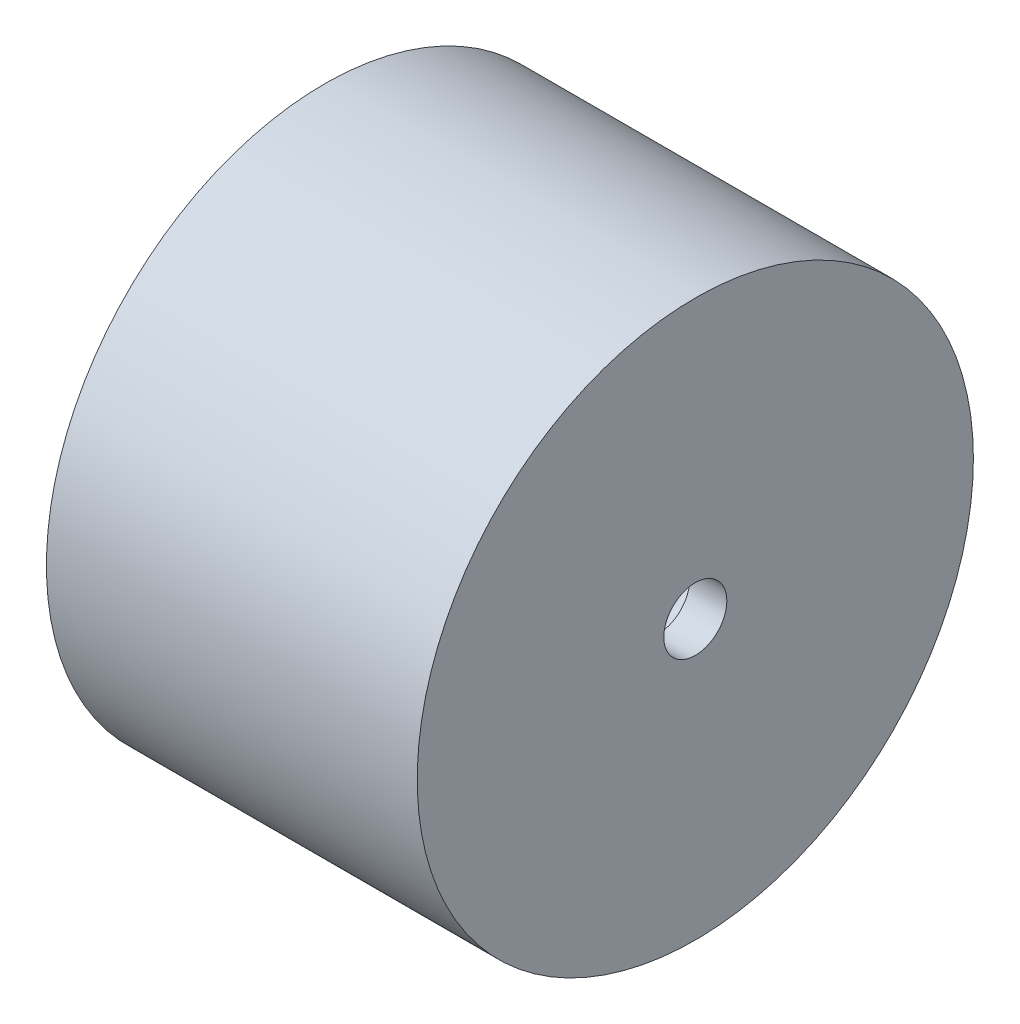
from build123d import *

# Parameters (mm, degrees)
SKETCH1_R           = 15
BOSS_EXTRUDE3_DEPTH = 20
SHELL2_T            = -2
SKETCH2_R           = 1.7
CUT_EXTRUDE1_DEPTH  = 2


with BuildPart() as part:
    # Sketch1 → Boss-Extrude3 (new body)
    with BuildSketch(Plane(origin=(0, 0, 0), x_dir=(0, 0, -1), z_dir=(1, 0, 0))):
        Circle(SKETCH1_R)
    extrude(amount=BOSS_EXTRUDE3_DEPTH)

    # Shell2
    shell2_openings = [part.faces().sort_by_distance(p)[0] for p in [
        (0, 0, 0),
    ]]
    offset(amount=SHELL2_T, openings=shell2_openings, kind=Kind.INTERSECTION)

    # Sketch2 → Cut-Extrude1 (cut)
    with BuildSketch(Plane(origin=(20, 0, 0), x_dir=(0, 0, -1), z_dir=(1, 0, 0))):
        Circle(SKETCH2_R)
    extrude(amount=-CUT_EXTRUDE1_DEPTH, mode=Mode.SUBTRACT)


solid = part.part
